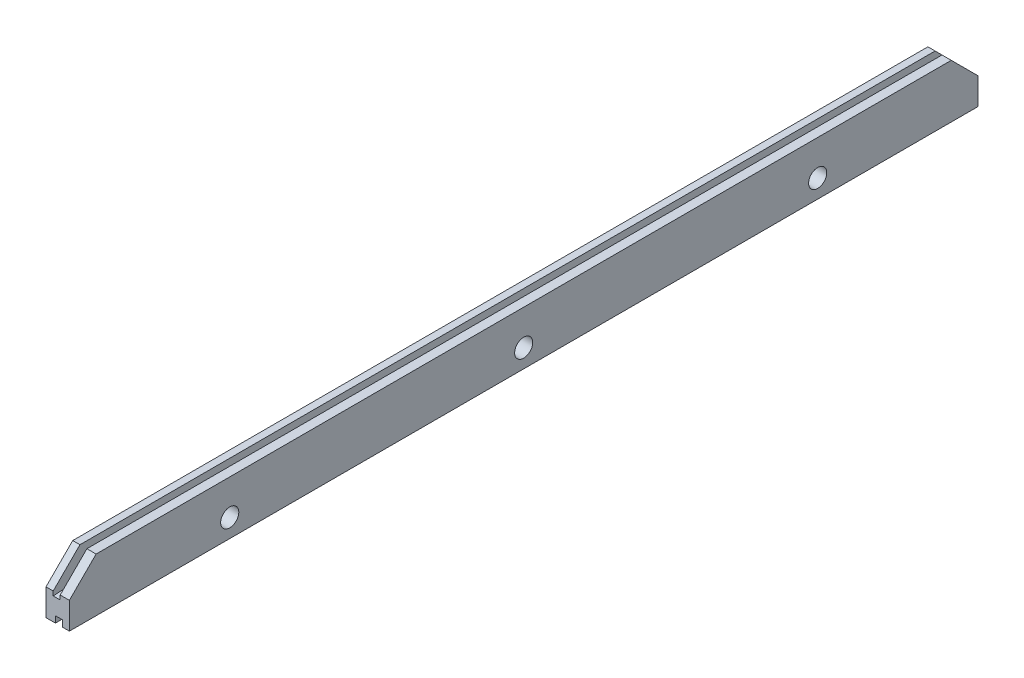
from build123d import *

# Parameters (mm, degrees)
SKETCH1_W                    = 5.55625
SKETCH1_H                    = 9.525
BOSS_EXTRUDE1_DEPTH          = 107.95
SKETCH17_W                   = 1.651
SKETCH17_H                   = 2.667
CUT_EXTRUDE8_DEPTH           = 216.9
SKETCH18_W                   = 1.651
SKETCH18_H                   = 1.524
CUT_EXTRUDE9_DEPTH           = 216.9
F_18_0_1695_DIAMETER_HOLE1_D = 4.3053
CHAMFER1_SIZE                = 1.524
CHAMFER1_SIZE2               = 25.4
CHAMFER2_SIZE                = 25.4
CHAMFER2_SIZE2               = 1.524
SKETCH25_W                   = 1.7145
SKETCH25_H                   = 215.9
SKETCH25_W_2                 = 2.19075
BOSS_EXTRUDE2_DEPTH          = 3.175
CHAMFER3_SIZE                = 6.35


with BuildPart() as part:
    # Sketch1 → Boss-Extrude1 (new body, symmetric)
    with BuildSketch(Plane.XY):
        with Locations((2.778125, 0)):
            Rectangle(SKETCH1_W, SKETCH1_H)
    extrude(amount=BOSS_EXTRUDE1_DEPTH, both=True)

    # Sketch17 → Cut-Extrude8 (cut, through all)
    with BuildSketch(Plane.XY.offset(107.95)):
        with Locations((2.54, 3.429)):
            Rectangle(SKETCH17_W, SKETCH17_H)
    extrude(amount=-CUT_EXTRUDE8_DEPTH, mode=Mode.SUBTRACT)

    # Sketch18 → Cut-Extrude9 (cut, through all)
    with BuildSketch(Plane.XY.offset(107.95)):
        with Locations((3.0607, -4.0005)):
            Rectangle(SKETCH18_W, SKETCH18_H)
    extrude(amount=-CUT_EXTRUDE9_DEPTH, mode=Mode.SUBTRACT)

    # #18 (0.1695) Diameter Hole1 (through all)
    with Locations(Plane.ZY):
        with Locations((69.85, -0.396875), (-69.85, -0.396875), (0, -0.396875)):
            Hole(F_18_0_1695_DIAMETER_HOLE1_D / 2)

    # Chamfer1
    chamfer1_edges = [part.edges().sort_by_distance(p)[0] for p in [
        (2.54, 2.0955, 107.95),
    ]]
    chamfer1_side = [part.faces().sort_by_distance(p)[0] for p in [
        (2.785461813, -0.109400999, 107.95),
    ]]
    chamfer(chamfer1_edges, length=CHAMFER1_SIZE, length2=CHAMFER1_SIZE2, reference=chamfer1_side[0])

    # Chamfer2
    chamfer2_edges = [part.edges().sort_by_distance(p)[0] for p in [
        (2.54, 2.0955, -107.95),
    ]]
    chamfer2_side = [part.faces().sort_by_distance(p)[0] for p in [
        (2.54, 2.0955, -12.7),
    ]]
    chamfer(chamfer2_edges, length=CHAMFER2_SIZE, length2=CHAMFER2_SIZE2, reference=chamfer2_side[0])

    # Sketch25 → Boss-Extrude2 (add)
    with BuildSketch(Plane(origin=(0, 4.7625, 0), x_dir=(1, 0, 0), z_dir=(0, 1, 0))):
        with Locations((0.85725, 0)):
            Rectangle(SKETCH25_W, SKETCH25_H)
        with Locations((4.460875, 0)):
            Rectangle(SKETCH25_W_2, SKETCH25_H)
    extrude(amount=BOSS_EXTRUDE2_DEPTH)

    # Chamfer3
    chamfer3_edges = [part.edges().sort_by_distance(p)[0] for p in [
        (4.460875, 7.9375, -107.95),
        (4.460875, 7.9375, 107.95),
        (0.85725, 7.9375, 107.95),
        (0.85725, 7.9375, -107.95),
    ]]
    chamfer(chamfer3_edges, length=CHAMFER3_SIZE)


solid = part.part
